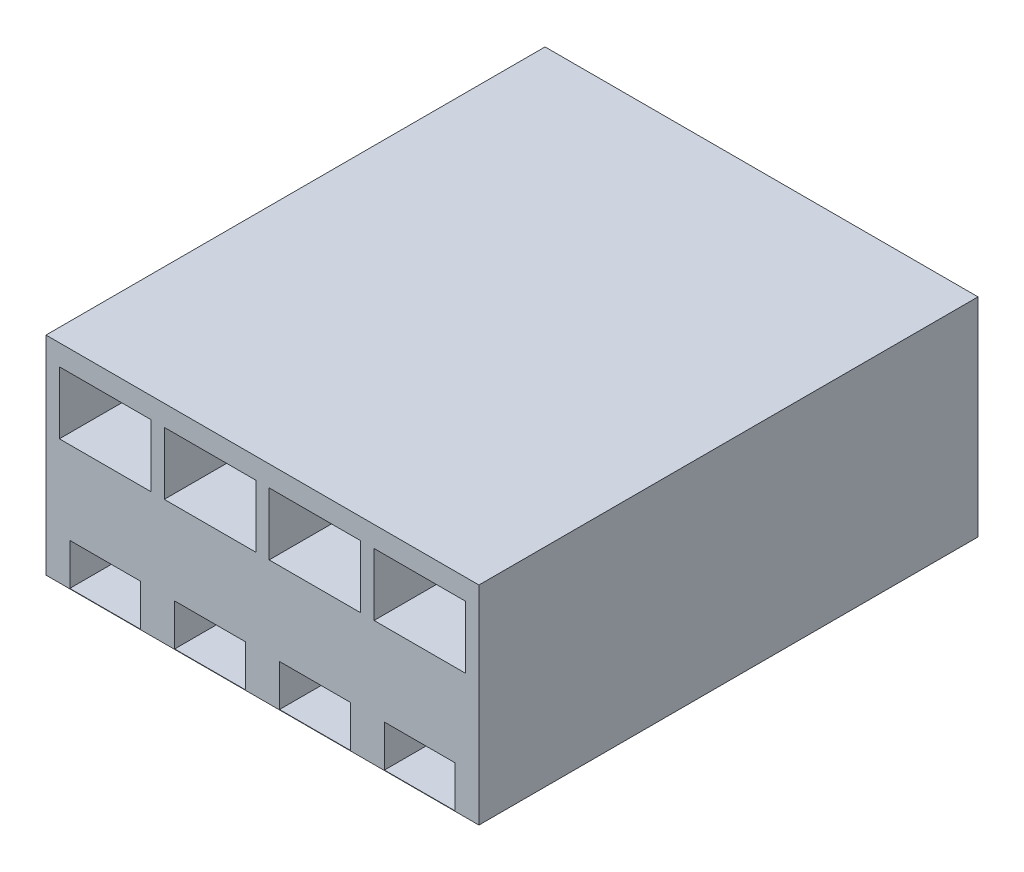
from build123d import *

# Parameters (mm, degrees)
SKETCH2_W            = 10.41
SKETCH2_H            = 5
SKETCH2_W_2          = 1.7
SKETCH2_H_2          = 1
SKETCH2_W_3          = 2.2
SKETCH2_H_3          = 1.5
BOSS_EXTRUDE1_DEPTH  = 12
SKETCH3_W            = 2.2
SKETCH3_H            = 1.5
SKETCH3_W_2          = 1.7
SKETCH3_H_2          = 1.01
BOSS_EXTRUDE10_DEPTH = 5


with BuildPart() as part:
    # Sketch2 → Boss-Extrude1 (new body)
    with BuildSketch(Plane.XY):
        with Locations((6.39898523, -2.364078969)):
            Rectangle(SKETCH2_W, SKETCH2_H)
        with Locations((10.18198523, -4.354078969)):
            Rectangle(SKETCH2_W_2, SKETCH2_H_2, mode=Mode.SUBTRACT)
        with Locations((2.61598523, -4.354078969)):
            Rectangle(SKETCH2_W_2, SKETCH2_H_2, mode=Mode.SUBTRACT)
        with Locations((10.18198523, -1.114078969)):
            Rectangle(SKETCH2_W_3, SKETCH2_H_3, mode=Mode.SUBTRACT)
        with Locations((2.61598523, -1.114078969)):
            Rectangle(SKETCH2_W_3, SKETCH2_H_3, mode=Mode.SUBTRACT)
        with Locations((7.65998523, -1.114078969)):
            Rectangle(SKETCH2_W_3, SKETCH2_H_3, mode=Mode.SUBTRACT)
        with Locations((5.13798523, -1.114078969)):
            Rectangle(SKETCH2_W_3, SKETCH2_H_3, mode=Mode.SUBTRACT)
        with Locations((5.13798523, -4.354078969)):
            Rectangle(SKETCH2_W_2, SKETCH2_H_2, mode=Mode.SUBTRACT)
        with Locations((7.65998523, -4.354078969)):
            Rectangle(SKETCH2_W_2, SKETCH2_H_2, mode=Mode.SUBTRACT)
    extrude(amount=BOSS_EXTRUDE1_DEPTH)

    # Sketch3 → Boss-Extrude10 (add)
    with BuildSketch(Plane.XY):
        with Locations((10.18198523, -1.114078969)):
            Rectangle(SKETCH3_W, SKETCH3_H)
        with Locations((7.65998523, -1.114078969)):
            Rectangle(SKETCH3_W, SKETCH3_H)
        with Locations((5.13798523, -1.114078969)):
            Rectangle(SKETCH3_W, SKETCH3_H)
        with Locations((2.61598523, -1.114078969)):
            Rectangle(SKETCH3_W, SKETCH3_H)
        with Locations((5.13798523, -4.359078969)):
            Rectangle(SKETCH3_W_2, SKETCH3_H_2)
        with Locations((2.61598523, -4.359078969)):
            Rectangle(SKETCH3_W_2, SKETCH3_H_2)
        with Locations((7.65998523, -4.359078969)):
            Rectangle(SKETCH3_W_2, SKETCH3_H_2)
        with Locations((10.18198523, -4.359078969)):
            Rectangle(SKETCH3_W_2, SKETCH3_H_2)
    extrude(amount=BOSS_EXTRUDE10_DEPTH)


solid = part.part
